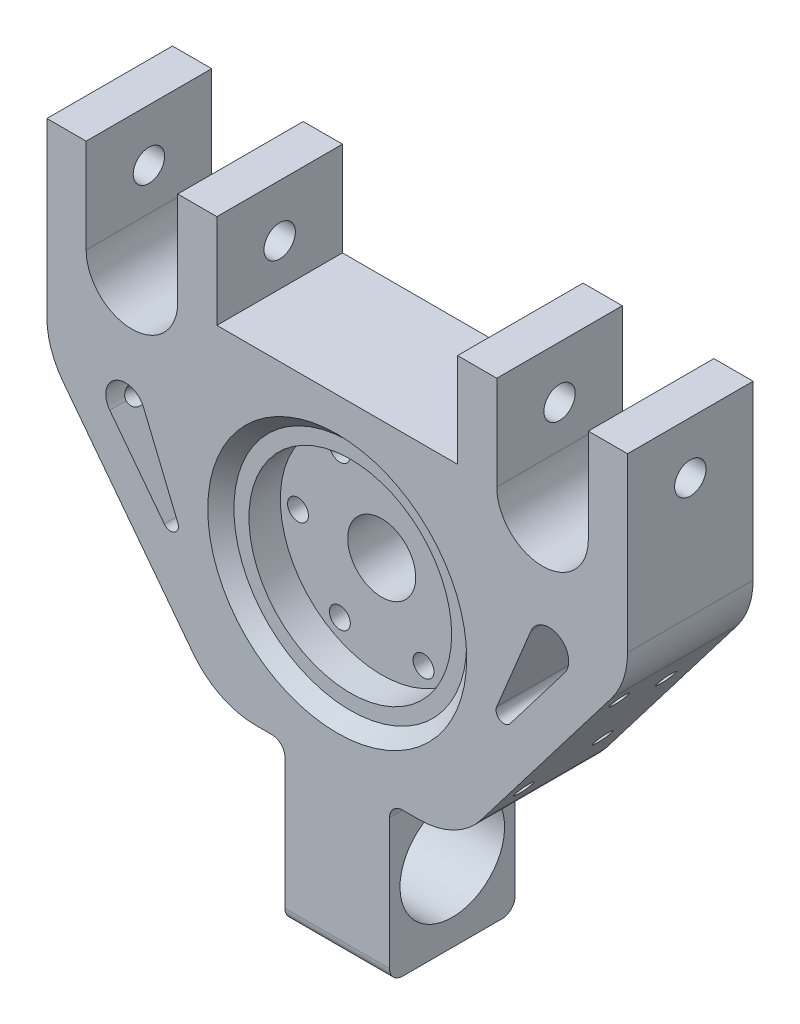
from build123d import *

# Parameters (mm, degrees)
SZKIC1_W                         = 222
SZKIC1_H                         = 125
SZKIC1_R                         = 13
SZKIC1_R_2                       = 4
DODANIE_WYCI_GNI_CIE1_DEPTH      = 13.5
DODANIE_WYCI_GNI_CIE1_DEPTH_BACK = 13.5
SZKIC4_W                         = 15
SZKIC4_H                         = 27
DODANIE_WYCI_GNI_CIE4_DEPTH      = 36
SZKIC13_R                        = 38.75
WYTNIJ_WYCI_GNI_CIE4_DEPTH       = 17
SZKIC15_R                        = 44.5
WYTNIJ_WYCI_GNI_CIE5_DEPTH       = 5
POCHYLENIE1_ANGLE                = 45
SZKIC16_R                        = 13
SZKIC16_R_2                      = 4
DODANIE_WYCI_GNI_CIE6_DEPTH      = 21
SZKIC5_R                         = 6
WYTNIJ_WYCI_GNI_CIE3_DEPTH       = 223
WYTNIJ_WYCI_GNI_CIE6_DEPTH       = 49
ZAOKR_GLENIE1_R                  = 30
ZAOKR_GLENIE2_R                  = 30
SZKIC19_W                        = 40
SZKIC19_H                        = 60
DODANIE_WYCI_GNI_CIE7_DEPTH      = 48
WYTNIJ_WYCI_GNI_CIE7_REACH       = 133
SZKIC23_R                        = 20
WYTNIJ_WYCI_GNI_CIE8_REACH       = 50
ZAOKR_GLENIE4_R                  = 5
ZAOKR_GLENIE5_R                  = 5
WYTNIJ_WYCI_GNI_CIE9_DEPTH       = 48
OTW_R_GWINTOWANY_M81_AT_2_COUNT  = 2
OTW_R_GWINTOWANY_M81_AT_2_PITCH  = 26
OTW_R_GWINTOWANY_M82_AT_2_COUNT  = 2
OTW_R_GWINTOWANY_M82_AT_2_PITCH  = 26


with BuildPart() as part:
    # Szkic1 → Dodanie-wyci_gni_cie1 (new body, two sides)
    with BuildSketch(Plane.XY) as dodanie_wyci_gni_cie1_sk:
        Rectangle(SZKIC1_W, SZKIC1_H)
        Circle(SZKIC1_R, mode=Mode.SUBTRACT)
        with Locations((-32, 0)):
            Circle(SZKIC1_R_2, mode=Mode.SUBTRACT)
        with Locations((-16, 27.712812921)):
            Circle(SZKIC1_R_2, mode=Mode.SUBTRACT)
        with Locations((16, 27.712812921)):
            Circle(SZKIC1_R_2, mode=Mode.SUBTRACT)
        with Locations((32, 0)):
            Circle(SZKIC1_R_2, mode=Mode.SUBTRACT)
        with Locations((16, -27.712812921)):
            Circle(SZKIC1_R_2, mode=Mode.SUBTRACT)
        with Locations((-16, -27.712812921)):
            Circle(SZKIC1_R_2, mode=Mode.SUBTRACT)
    extrude(amount=DODANIE_WYCI_GNI_CIE1_DEPTH)
    extrude(dodanie_wyci_gni_cie1_sk.sketch, amount=-DODANIE_WYCI_GNI_CIE1_DEPTH_BACK)

    # Szkic4 → Dodanie-wyci_gni_cie4 (add)
    with BuildSketch(Plane(origin=(0, 62.5, 0), x_dir=(1, 0, 0), z_dir=(0, 1, 0))):
        with Locations((-103.5, 0)):
            Rectangle(SZKIC4_W, SZKIC4_H)
        with Locations((-53.5, 0)):
            Rectangle(SZKIC4_W, SZKIC4_H)
        with Locations((53.5, 0)):
            Rectangle(SZKIC4_W, SZKIC4_H)
        with Locations((103.5, 0)):
            Rectangle(SZKIC4_W, SZKIC4_H)
    extrude(amount=DODANIE_WYCI_GNI_CIE4_DEPTH)

    # Szkic13 → Wytnij-wyci_gni_cie4 (cut)
    with BuildSketch(Plane.XY.offset(13.5)):
        Circle(SZKIC13_R)
    extrude(amount=-WYTNIJ_WYCI_GNI_CIE4_DEPTH, mode=Mode.SUBTRACT)

    # Szkic15 → Wytnij-wyci_gni_cie5 (cut)
    with BuildSketch(Plane.XY.offset(13.5)):
        Circle(SZKIC15_R)
    extrude(amount=-WYTNIJ_WYCI_GNI_CIE5_DEPTH, mode=Mode.SUBTRACT)

    # Pochylenie1
    pochylenie1_faces = [part.faces().sort_by_distance(p)[0] for p in [
        (-44.5, 0, 11),
    ]]
    draft(pochylenie1_faces, Plane.XY.offset(8.5), POCHYLENIE1_ANGLE)

    # Szkic16 → Dodanie-wyci_gni_cie6 (add)
    with BuildSketch(Plane(origin=(0, 0, -13.5), x_dir=(-1, 0, 0), z_dir=(0, 0, -1))):
        Polygon((-111, 98.5), (-111, -62.5), (111, -62.5), (111, 98.5), (96, 98.5), (96, 62.5), (61, 62.5), (61, 98.5), (46, 98.5), (46, 62.5), (-46, 62.5), (-46, 98.5), (-61, 98.5), (-61, 62.5), (-96, 62.5), (-96, 98.5), align=None)
        Circle(SZKIC16_R, mode=Mode.SUBTRACT)
        with Locations((32, 0)):
            Circle(SZKIC16_R_2, mode=Mode.SUBTRACT)
        with Locations((16, 27.712812921)):
            Circle(SZKIC16_R_2, mode=Mode.SUBTRACT)
        with Locations((-16, 27.712812921)):
            Circle(SZKIC16_R_2, mode=Mode.SUBTRACT)
        with Locations((-32, 0)):
            Circle(SZKIC16_R_2, mode=Mode.SUBTRACT)
        with Locations((-16, -27.712812921)):
            Circle(SZKIC16_R_2, mode=Mode.SUBTRACT)
        with Locations((16, -27.712812921)):
            Circle(SZKIC16_R_2, mode=Mode.SUBTRACT)
    extrude(amount=DODANIE_WYCI_GNI_CIE6_DEPTH)

    # Szkic5 → Wytnij-wyci_gni_cie3 (cut, through all)
    with BuildSketch(Plane.ZY.offset(111)):
        with Locations((-10.5, 78.5)):
            Circle(SZKIC5_R)
    extrude(amount=-WYTNIJ_WYCI_GNI_CIE3_DEPTH, mode=Mode.SUBTRACT)

    # Szkic18 → Wytnij-wyci_gni_cie6 (cut, through all)
    with BuildSketch(Plane(origin=(0, 0, -34.5), x_dir=(-1, 0, 0), z_dir=(0, 0, -1))):
        Polygon((111, 22.5), (46, -62.5), (111, -62.5), align=None)
        Polygon((-111, -62.5), (-46, -62.5), (-111, 22.5), align=None)
    extrude(amount=-WYTNIJ_WYCI_GNI_CIE6_DEPTH, mode=Mode.SUBTRACT)

    # Zaokr_glenie1
    zaokr_glenie1_edges = [part.edges().sort_by_distance(p)[0] for p in [
        (-111, 22.5, -10.5),
    ]]
    fillet(zaokr_glenie1_edges, radius=ZAOKR_GLENIE1_R)

    # Zaokr_glenie2
    zaokr_glenie2_edges = [part.edges().sort_by_distance(p)[0] for p in [
        (-46, -62.5, -10.5),
        (111, 22.5, -10.5),
        (46, -62.5, -10.5),
    ]]
    fillet(zaokr_glenie2_edges, radius=ZAOKR_GLENIE2_R)

    # Szkic19 → Dodanie-wyci_gni_cie7 (add)
    with BuildSketch(Plane(origin=(0, 0, -34.5), x_dir=(-1, 0, 0), z_dir=(0, 0, -1))):
        with Locations((0, -92.5)):
            Rectangle(SZKIC19_W, SZKIC19_H)
    extrude(amount=-DODANIE_WYCI_GNI_CIE7_DEPTH)

    # Szkic23 → Wytnij-wyci_gni_cie7 (cut, up to next)
    with BuildSketch(Plane(origin=(20, 0, 0), x_dir=(0, 0, -1), z_dir=(1, 0, 0)), mode=Mode.PRIVATE) as wytnij_wyci_gni_cie7_sk1:
        with Locations((10.5, -92.5)):
            Circle(SZKIC23_R)
    wytnij_wyci_gni_cie7_tool1 = extrude(wytnij_wyci_gni_cie7_sk1.sketch, amount=-WYTNIJ_WYCI_GNI_CIE7_REACH, mode=Mode.PRIVATE) & part.part
    add(wytnij_wyci_gni_cie7_tool1.solids().sort_by_distance((20, -92.5, -10.5))[0], mode=Mode.SUBTRACT)

    # Szkic24 → Wytnij-wyci_gni_cie8 (cut, up to next)
    with BuildSketch(Plane(origin=(0, 0, -34.5), x_dir=(-1, 0, 0), z_dir=(0, 0, -1)), mode=Mode.PRIVATE) as wytnij_wyci_gni_cie8_sk1:
        with BuildLine():
            Line((-96, 62.5), (-61, 62.5))
            ThreePointArc((-61, 62.5), (-78.5, 45), (-96, 62.5))
        make_face()
    wytnij_wyci_gni_cie8_tool1 = extrude(wytnij_wyci_gni_cie8_sk1.sketch, amount=-WYTNIJ_WYCI_GNI_CIE8_REACH, mode=Mode.PRIVATE) & part.part
    add(wytnij_wyci_gni_cie8_tool1.solids().sort_by_distance((78.5, 55.072769, -34.5))[0], mode=Mode.SUBTRACT)
    # Szkic24 → Wytnij-wyci_gni_cie8 (cut, up to next)
    with BuildSketch(Plane(origin=(0, 0, -34.5), x_dir=(-1, 0, 0), z_dir=(0, 0, -1)), mode=Mode.PRIVATE) as wytnij_wyci_gni_cie8_sk2:
        with BuildLine():
            Line((61, 62.5), (96, 62.5))
            ThreePointArc((96, 62.5), (78.5, 45), (61, 62.5))
        make_face()
    wytnij_wyci_gni_cie8_tool2 = extrude(wytnij_wyci_gni_cie8_sk2.sketch, amount=-WYTNIJ_WYCI_GNI_CIE8_REACH, mode=Mode.PRIVATE) & part.part
    add(wytnij_wyci_gni_cie8_tool2.solids().sort_by_distance((-78.5, 55.072769, -34.5))[0], mode=Mode.SUBTRACT)

    # Zaokr_glenie4
    zaokr_glenie4_edges = [part.edges().sort_by_distance(p)[0] for p in [
        (20, -62.5, -10.5),
        (-20, -62.5, -10.5),
    ]]
    fillet(zaokr_glenie4_edges, radius=ZAOKR_GLENIE4_R)

    # Zaokr_glenie5
    zaokr_glenie5_edges = [part.edges().sort_by_distance(p)[0] for p in [
        (0, -122.5, -34.5),
        (0, -122.5, 13.5),
    ]]
    fillet(zaokr_glenie5_edges, radius=ZAOKR_GLENIE5_R)

    # Szkic25 → Wytnij-wyci_gni_cie9 (cut)
    with BuildSketch(Plane.XY.offset(13.5)):
        with BuildLine():
            Line((-60.951491344, -10.353512592), (-74.069286372, 21.36621852))
            ThreePointArc((-74.069286372, 21.36621852), (-84.742802137, 24.999340902), (-86.957683747, 13.944124193))
            Line((-86.957683747, 13.944124193), (-66.106850294, -13.322350323))
            ThreePointArc((-66.106850294, -13.322350323), (-62.22665594, -14.099736361), (-60.951491344, -10.353512592))
        make_face()
        with BuildLine():
            Line((66.106850294, -13.322350323), (86.957683747, 13.944124193))
            ThreePointArc((86.957683747, 13.944124193), (84.742802137, 24.999340902), (74.069286372, 21.36621852))
            Line((74.069286372, 21.36621852), (60.951491344, -10.353512592))
            ThreePointArc((60.951491344, -10.353512592), (62.22665594, -14.099736361), (66.106850294, -13.322350323))
        make_face()
    extrude(amount=-WYTNIJ_WYCI_GNI_CIE9_DEPTH, mode=Mode.SUBTRACT)

    # Szkic28 → Otw_r gwintowany M81 (revolve, cut)
    with BuildSketch(Plane(origin=(-92.067147824, -2.258345153, -20.15), x_dir=(0.607450108, -0.794357833, 0), z_dir=(0, 0, 1))):
        Polygon((0, 0), (0, 47.042926105), (3.4, 45), (3.4, 0), align=None)
    otw_r_gwintowany_m81 = revolve(axis=Axis((-97.111320063, -6.115653336, -20.15), (0.794357833, 0.607450108, 0)), mode=Mode.SUBTRACT)

    # Otw_r gwintowany M81 at 2: Otw_r gwintowany M81 ×2
    with Locations(*[Vector(-0.233634657, 0.305522243, 0.923076923) * (i * OTW_R_GWINTOWANY_M81_AT_2_PITCH) for i in range(1, OTW_R_GWINTOWANY_M81_AT_2_COUNT)]):
        add(otw_r_gwintowany_m81, mode=Mode.SUBTRACT)

    # Szkic30 → Otw_r gwintowany M82 (revolve, cut)
    with BuildSketch(Plane(origin=(-61.694642445, -41.976236802, 3.85), x_dir=(0.607450108, -0.794357833, 0), z_dir=(0, 0, 1))):
        Polygon((0, 0), (0, 27.042926105), (3.4, 25), (3.4, 0), align=None)
    otw_r_gwintowany_m82 = revolve(axis=Axis((-66.738814685, -45.833544985, 3.85), (0.794357833, 0.607450108, 0)), mode=Mode.SUBTRACT)

    # Otw_r gwintowany M82 at 2: Otw_r gwintowany M82 ×2
    with Locations(*[Vector(-0.233634657, 0.305522243, -0.923076923) * (i * OTW_R_GWINTOWANY_M82_AT_2_PITCH) for i in range(1, OTW_R_GWINTOWANY_M82_AT_2_COUNT)]):
        add(otw_r_gwintowany_m82, mode=Mode.SUBTRACT)

    # Lustro1: Otw_r gwintowany M82, Otw_r gwintowany M81 across plane
    add(otw_r_gwintowany_m82.mirror(Plane(origin=(0, 0, 0), x_dir=(0, 0, 1), z_dir=(1, 0, 0))), mode=Mode.SUBTRACT)
    add(otw_r_gwintowany_m81.mirror(Plane(origin=(0, 0, 0), x_dir=(0, 0, 1), z_dir=(1, 0, 0))), mode=Mode.SUBTRACT)

    # Lustro1 copy 1 sketch → Lustro1 copy 1 (revolve, cut)
    with BuildSketch(Plane(origin=(67.769143521, -34.032658472, -20.15), x_dir=(-0.607450108, -0.794357833, 0), z_dir=(0, 0, 1))):
        Polygon((0, 0), (0, -27.042926105), (3.4, -25), (3.4, 0), align=None)
    revolve(axis=Axis((72.813315761, -37.889966655, -20.15), (0.794357833, -0.607450108, 0)), mode=Mode.SUBTRACT)

    # Lustro1 copy 2 sketch → Lustro1 copy 2 (revolve, cut)
    with BuildSketch(Plane(origin=(98.1416489, 5.685233176, 3.85), x_dir=(-0.607450108, -0.794357833, 0), z_dir=(0, 0, 1))):
        Polygon((0, 0), (0, -47.042926105), (3.4, -45), (3.4, 0), align=None)
    revolve(axis=Axis((103.185821139, 1.827924993, 3.85), (0.794357833, -0.607450108, 0)), mode=Mode.SUBTRACT)


solid = part.part
